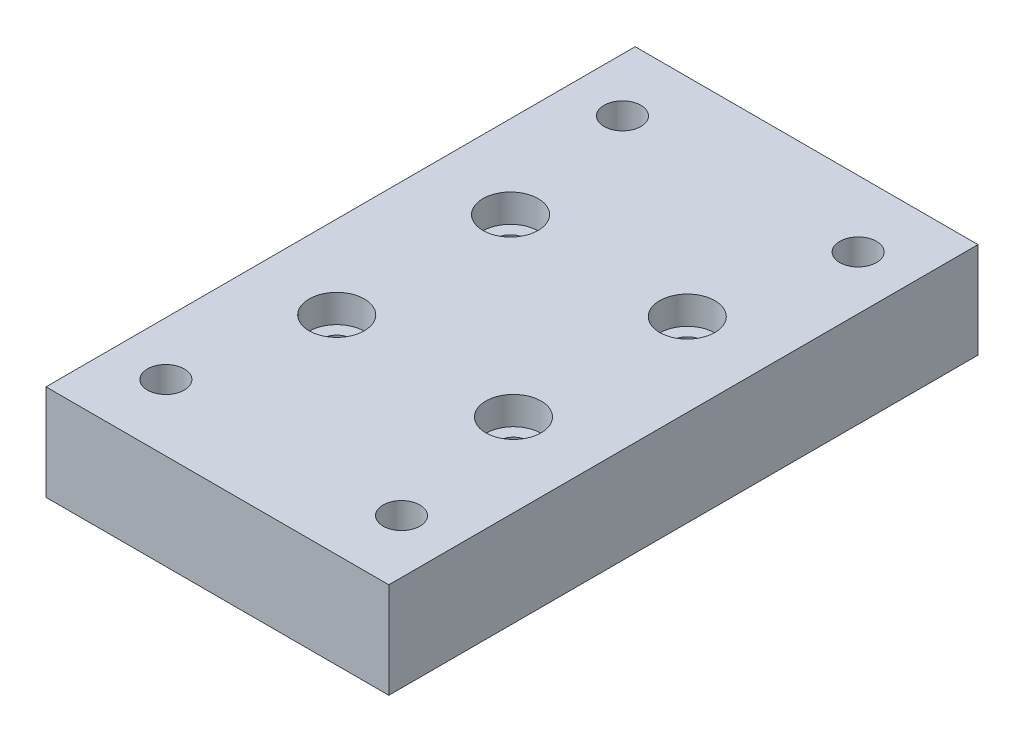
from build123d import *

# Parameters (mm, degrees)
SKETCH1_W                                       = 59.1185
SKETCH1_H                                       = 101.6
BOSS_EXTRUDE1_DEPTH                             = 16.51
CBORE_FOR_10_SOCKET_HEAD_CAP_SCREW1_D           = 5.1054
CBORE_FOR_10_SOCKET_HEAD_CAP_SCREW1_DEPTH       = 15.24
CBORE_FOR_10_SOCKET_HEAD_CAP_SCREW1_CBORE_D     = 9.525
CBORE_FOR_10_SOCKET_HEAD_CAP_SCREW1_CBORE_DEPTH = 4.826
F_1_4_0_25_DIAMETER_HOLE1_D                     = 6.35


with BuildPart() as part:
    # Sketch1 → Boss-Extrude1 (new body)
    with BuildSketch(Plane(origin=(0, 0, 0), x_dir=(1, 0, 0), z_dir=(0, 1, 0))):
        Rectangle(SKETCH1_W, SKETCH1_H)
    extrude(amount=BOSS_EXTRUDE1_DEPTH)

    # CBORE for #10 Socket Head Cap Screw1
    with Locations(Plane(origin=(-223.3968133, 16.51, 0), x_dir=(0, 0, 1), z_dir=(0, 1, 0))):
        with Locations((-14.986, 208.1568133), (14.986, 208.1568133), (14.986, 238.6368133), (-14.986, 238.6368133)):
            CounterBoreHole(CBORE_FOR_10_SOCKET_HEAD_CAP_SCREW1_D / 2, CBORE_FOR_10_SOCKET_HEAD_CAP_SCREW1_CBORE_D / 2, CBORE_FOR_10_SOCKET_HEAD_CAP_SCREW1_CBORE_DEPTH, depth=CBORE_FOR_10_SOCKET_HEAD_CAP_SCREW1_DEPTH)

    # 1/4 (0.25) Diameter Hole1 (through all)
    with Locations(Plane(origin=(0, 16.51, 0), x_dir=(1, 0, 0), z_dir=(0, 1, 0))):
        with Locations((20.32, -39.37), (-20.32, -39.37), (-20.32, 39.37), (20.32, 39.37)):
            Hole(F_1_4_0_25_DIAMETER_HOLE1_D / 2)


solid = part.part
